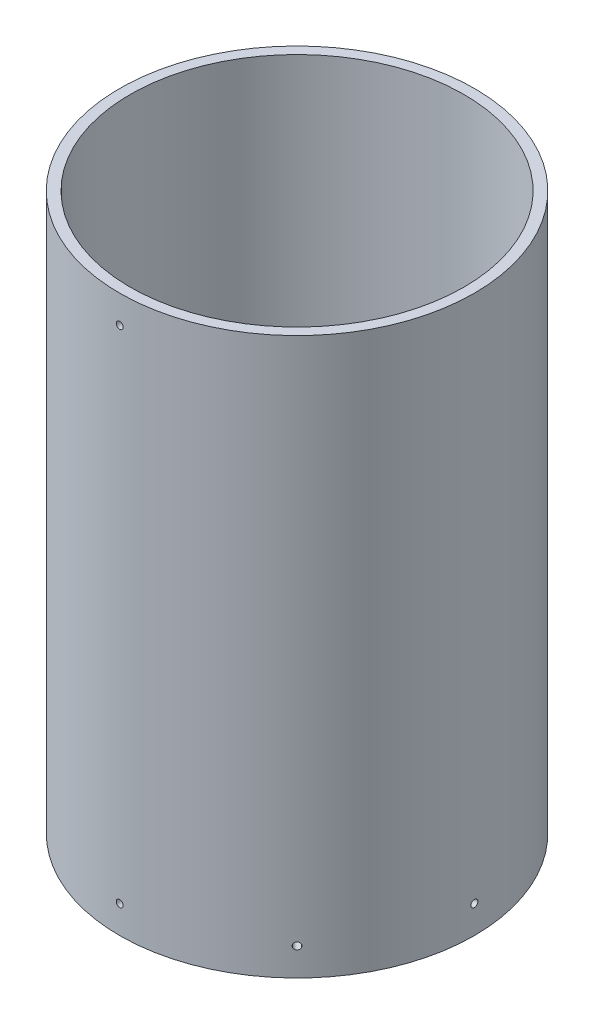
from build123d import *

# Parameters (mm, degrees)
SKETCH12_R                    = 161.925
SKETCH12_R_2                  = 152.4
PIPE_STANDARD_S40_P12_2_DEPTH = 508
SKETCH13_R                    = 3.175
CUT_EXTRUDE1_DEPTH            = 558.228329547
SKETCH15_R                    = 3.175
CUT_EXTRUDE2_DEPTH            = 558.228329706
SKETCH16_R                    = 3.175
CUT_EXTRUDE3_DEPTH            = 558.228329706


with BuildPart() as part:
    # Sketch12 → Pipe (standard, s40) P12(2) (new body)
    with BuildSketch(Plane.XZ):
        Circle(SKETCH12_R)
        Circle(SKETCH12_R_2, mode=Mode.SUBTRACT)
    extrude(amount=PIPE_STANDARD_S40_P12_2_DEPTH)

    # Sketch13 → Cut-Extrude1 (cut, through all)
    with BuildSketch(Plane.XY):
        with Locations(Location((0, -482.6, 0), (0, 0, 180))):
            Circle(SKETCH13_R)
        with Locations(Location((0, -25.4, 0), (0, 0, 180))):
            Circle(SKETCH13_R)
    extrude(amount=CUT_EXTRUDE1_DEPTH, mode=Mode.SUBTRACT)

    # Sketch15 → Cut-Extrude2 (cut, through all)
    with BuildSketch(Plane(origin=(0, 0, 0), x_dir=(0, -1, 0), z_dir=(-0.7071067811865438, 0, -0.7071067811865512))):
        with Locations(Location((482.6, 0, 0), (0, 0, 90))):
            Circle(SKETCH15_R)
    extrude(amount=-CUT_EXTRUDE2_DEPTH, mode=Mode.SUBTRACT)

    # Sketch16 → Cut-Extrude3 (cut, through all)
    with BuildSketch(Plane(origin=(0, 0, 0), x_dir=(0, 0, -1), z_dir=(1, 0, 0))):
        with Locations(Location((0, -482.6, 0), (0, 0, 90.000000043))):
            Circle(SKETCH16_R)
    extrude(amount=CUT_EXTRUDE3_DEPTH, mode=Mode.SUBTRACT)


solid = part.part
